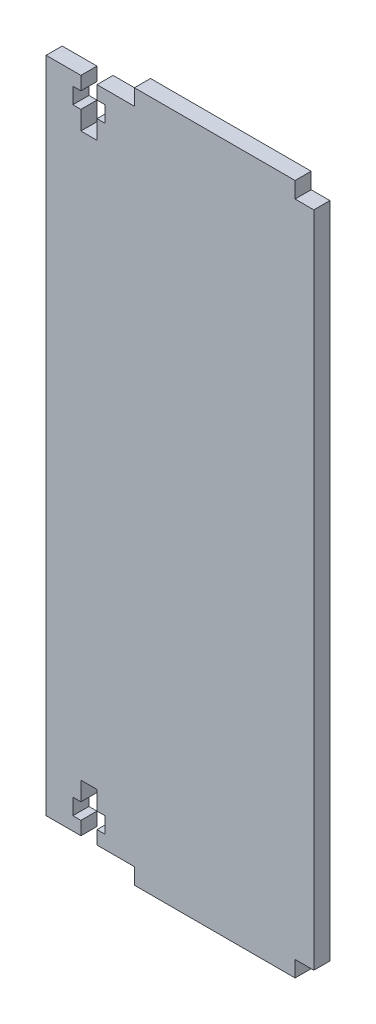
from build123d import *

# Parameters (mm, degrees)
BOSS_EXTRUDE1_DEPTH = 3


with BuildPart() as part:
    # Sketch1 → Boss-Extrude1 (new body)
    with BuildSketch(Plane.XY):
        Polygon((-15.5, 61.5), (-8.5, 61.5), (-8.5, 64.5), (21.5, 64.5), (21.5, 61.5), (25, 61.5), (25, -61.5), (21.5, -61.5), (21.5, -64.5), (-8.5, -64.5), (-8.5, -61.5), (-15.5, -61.5), (-15.5, -59), (-14, -59), (-14, -56), (-15.5, -56), (-15.5, -52.5), (-18.5, -52.5), (-18.5, -56), (-20, -56), (-20, -59), (-18.5, -59), (-18.5, -61.5), (-25, -61.5), (-25, 61.5), (-18.5, 61.5), (-18.5, 59), (-20, 59), (-20, 56), (-18.5, 56), (-18.5, 52.5), (-15.5, 52.5), (-15.5, 56), (-14, 56), (-14, 59), (-15.5, 59), align=None)
    extrude(amount=BOSS_EXTRUDE1_DEPTH)


solid = part.part
